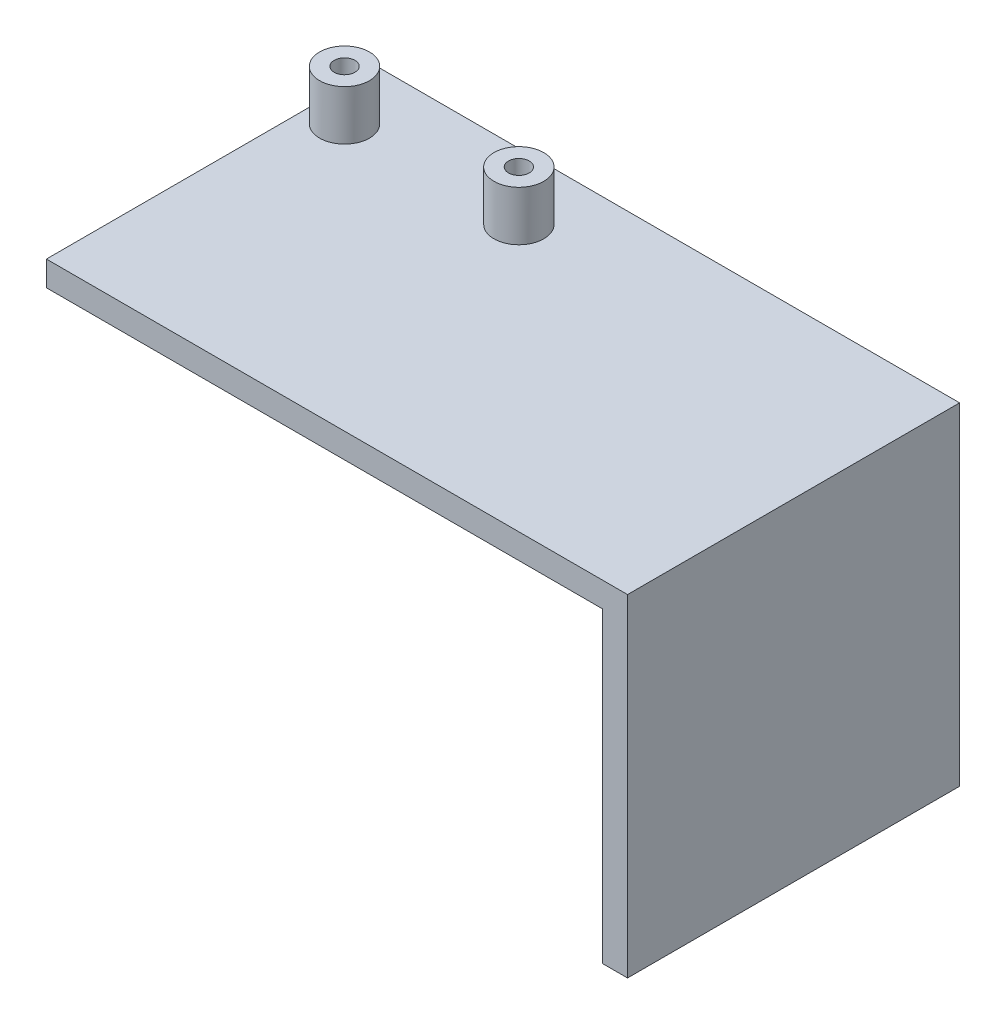
from build123d import *

# Parameters (mm, degrees)
SKETCH1_W                       = 70
SKETCH1_H                       = 40
BOSS_EXTRUDE1_DEPTH             = 40
SKETCH2_W                       = 40
SKETCH2_H                       = 37
CUT_EXTRUDE1_DEPTH              = 67
SKETCH4_R                       = 3
BOSS_EXTRUDE2_DEPTH             = 6
TAP_DRILL_FOR_M3X0_5_TAP2_D     = 2.5
TAP_DRILL_FOR_M3X0_5_TAP2_DEPTH = 6
TAP_DRILL_FOR_M3X0_5_TAP2_TIP   = 0.751075774


with BuildPart() as part:
    # Sketch1 → Boss-Extrude1 (new body)
    with BuildSketch(Plane(origin=(0, 0, 0), x_dir=(1, 0, 0), z_dir=(0, 1, 0))):
        Rectangle(SKETCH1_W, SKETCH1_H)
    extrude(amount=BOSS_EXTRUDE1_DEPTH)

    # Sketch2 → Cut-Extrude1 (cut)
    with BuildSketch(Plane.ZY.offset(35)):
        with Locations((0, 18.5)):
            Rectangle(SKETCH2_W, SKETCH2_H)
    extrude(amount=-CUT_EXTRUDE1_DEPTH, mode=Mode.SUBTRACT)

    # Sketch4 → Boss-Extrude2 (add)
    with BuildSketch(Plane(origin=(0, 40, 0), x_dir=(1, 0, 0), z_dir=(0, 1, 0))):
        with Locations((-31.149822544, 12.062768)):
            Circle(SKETCH4_R)
        with Locations((-10.149822544, 12.062768)):
            Circle(SKETCH4_R)
    extrude(amount=BOSS_EXTRUDE2_DEPTH)

    # Tap Drill for M3x0.5 Tap2
    with Locations(Plane(origin=(0, 46, 0), x_dir=(1, 0, 0), z_dir=(0, 1, 0))):
        with Locations((-31.149822544, 12.062768), (-10.149822544, 12.062768)):
            Hole(TAP_DRILL_FOR_M3X0_5_TAP2_D / 2, depth=TAP_DRILL_FOR_M3X0_5_TAP2_DEPTH)
            with Locations((0, 0, -(TAP_DRILL_FOR_M3X0_5_TAP2_DEPTH + TAP_DRILL_FOR_M3X0_5_TAP2_TIP / 2))):  # 118° drill point
                Cone(0, TAP_DRILL_FOR_M3X0_5_TAP2_D / 2, TAP_DRILL_FOR_M3X0_5_TAP2_TIP, mode=Mode.SUBTRACT)


solid = part.part
